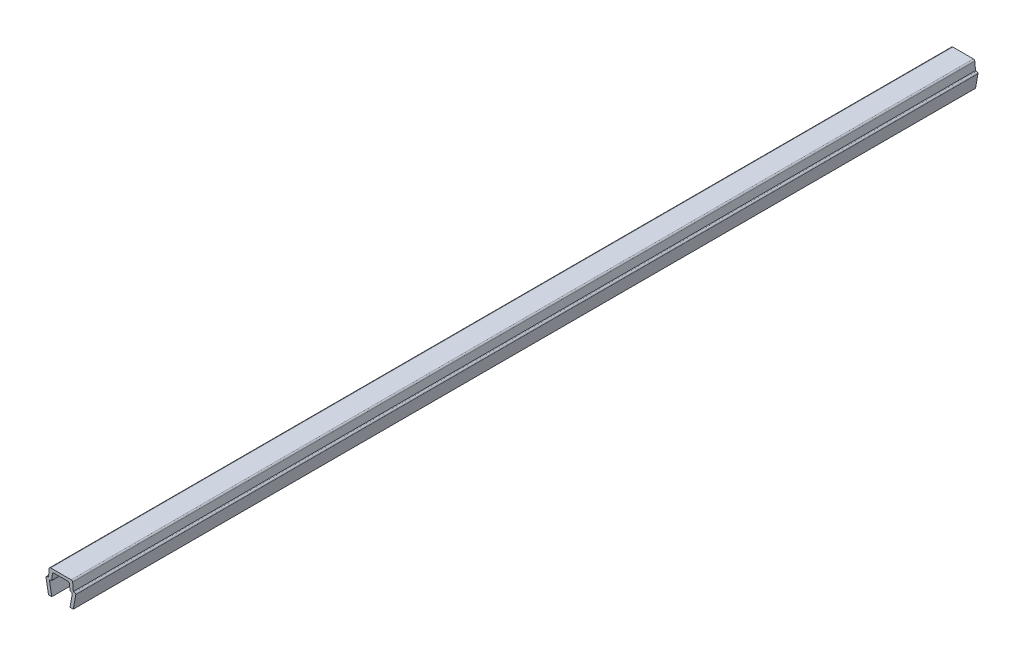
from build123d import *

# Parameters (mm, degrees)
BOSS_EXTRUDE1_DEPTH = 109


with BuildPart() as part:
    # Sketch1 → Boss-Extrude1 (new body, symmetric)
    with BuildSketch(Plane.XY):
        with BuildLine():
            Line((-3.6, 3.35), (-3, 0))
            Line((-3, 0), (-2.2, 0))
            Line((-2.2, 0), (-2.735217071, 2.988295315))
            ThreePointArc((-2.735217071, 2.988295315), (-2.659117427, 3.274614514), (-2.390699246, 3.4))
            Line((-2.390699246, 3.4), (-2.2, 3.4))
            Line((-2.2, 3.4), (-2.070472639, 4.88050451))
            ThreePointArc((-2.070472639, 4.88050451), (-1.958261067, 5.108047068), (-1.721804495, 5.2))
            Line((-1.721804495, 5.2), (1.721804495, 5.2))
            ThreePointArc((1.721804495, 5.2), (1.958261067, 5.108047068), (2.070472639, 4.88050451))
            Line((2.070472639, 4.88050451), (2.2, 3.4))
            Line((2.2, 3.4), (2.390699246, 3.4))
            ThreePointArc((2.390699246, 3.4), (2.659117427, 3.274614514), (2.735217071, 2.988295315))
            Line((2.735217071, 2.988295315), (2.2, 0))
            Line((2.2, 0), (3, 0))
            Line((3, 0), (3.6, 3.35))
            ThreePointArc((3.6, 3.35), (3.497487373, 3.597487373), (3.25, 3.7))
            Line((3.25, 3.7), (3, 3.7))
            Line((3, 3.7), (2.835477174, 5.58050451))
            ThreePointArc((2.835477174, 5.58050451), (2.723265602, 5.808047068), (2.486809029, 5.9))
            Line((2.486809029, 5.9), (-2.486809029, 5.9))
            ThreePointArc((-2.486809029, 5.9), (-2.723265602, 5.808047068), (-2.835477174, 5.58050451))
            Line((-2.835477174, 5.58050451), (-3, 3.7))
            Line((-3, 3.7), (-3.25, 3.7))
            ThreePointArc((-3.25, 3.7), (-3.497487373, 3.597487373), (-3.6, 3.35))
        make_face()
    extrude(amount=BOSS_EXTRUDE1_DEPTH, both=True)


solid = part.part
